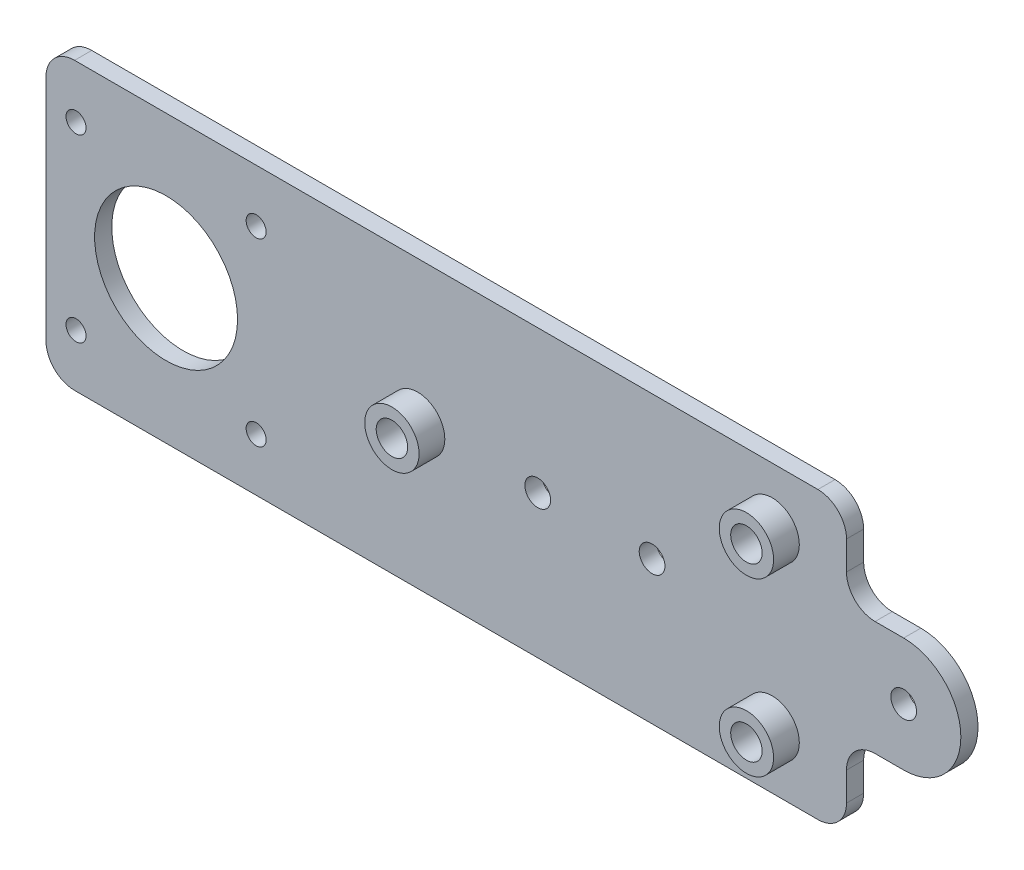
from build123d import *

# Parameters (mm, degrees)
BOSS_EXTRUDE1_DEPTH = 3
SKETCH2_R           = 1.75
SKETCH2_R_2         = 12.5
SKETCH2_R_3         = 2.75
CUT_EXTRUDE1_DEPTH  = 3
SKETCH3_R           = 4.75
SKETCH3_R_2         = 2.75
BOSS_EXTRUDE2_DEPTH = 4.5
SKETCH4_R           = 2.25
BOSS_EXTRUDE3_DEPTH = 3
FILLET1_R           = 5
SKETCH5_R           = 2.25
CUT_EXTRUDE2_DEPTH  = 4


with BuildPart() as part:
    # Sketch1 → Boss-Extrude1 (new body)
    with BuildSketch(Plane.XY):
        with BuildLine():
            Line((-65, 25), (65, 25))
            ThreePointArc((65, 25), (68.535533906, 23.535533906), (70, 20))
            Line((70, 20), (70, -20))
            ThreePointArc((70, -20), (68.535533906, -23.535533906), (65, -25))
            Line((65, -25), (-65, -25))
            ThreePointArc((-65, -25), (-68.535533906, -23.535533906), (-70, -20))
            Line((-70, -20), (-70, 20))
            ThreePointArc((-70, 20), (-68.535533906, 23.535533906), (-65, 25))
        make_face()
    extrude(amount=BOSS_EXTRUDE1_DEPTH)

    # Sketch2 → Cut-Extrude1 (cut)
    with BuildSketch(Plane.XY.offset(3)):
        with Locations((-64.75, 15.75)):
            Circle(SKETCH2_R)
        with Locations((-33.25, 15.75)):
            Circle(SKETCH2_R)
        with Locations((-64.75, -15.75)):
            Circle(SKETCH2_R)
        with Locations((-33.25, -15.75)):
            Circle(SKETCH2_R)
        with Locations((-49, 0)):
            Circle(SKETCH2_R_2)
        with Locations((57, 15)):
            Circle(SKETCH2_R_3)
        with Locations((57, -15)):
            Circle(SKETCH2_R_3)
        with Locations((-5, 0)):
            Circle(SKETCH2_R_3)
    extrude(amount=-CUT_EXTRUDE1_DEPTH, mode=Mode.SUBTRACT)

    # Sketch3 → Boss-Extrude2 (add)
    with BuildSketch(Plane.XY.offset(3)):
        with Locations((57, 15)):
            Circle(SKETCH3_R)
        with Locations((57, 15)):
            Circle(SKETCH3_R_2, mode=Mode.SUBTRACT)
        with Locations((-5, 0)):
            Circle(SKETCH3_R)
        with Locations((-5, 0)):
            Circle(SKETCH3_R_2, mode=Mode.SUBTRACT)
        with Locations((57, -15)):
            Circle(SKETCH3_R)
        with Locations((57, -15)):
            Circle(SKETCH3_R_2, mode=Mode.SUBTRACT)
    extrude(amount=BOSS_EXTRUDE2_DEPTH)

    # Sketch4 → Boss-Extrude3 (add)
    with BuildSketch(Plane.XY):
        with BuildLine():
            Line((70, 10), (70, -10))
            Line((70, -10), (80, -10))
            ThreePointArc((80, -10), (90, 0), (80, 10))
            Line((80, 10), (70, 10))
        make_face()
        with Locations((80, 0)):
            Circle(SKETCH4_R, mode=Mode.SUBTRACT)
    extrude(amount=BOSS_EXTRUDE3_DEPTH)

    # Fillet1
    fillet1_edges = [part.edges().sort_by_distance(p)[0] for p in [
        (70, -10, 1.5),
        (70, 10, 1.5),
    ]]
    fillet(fillet1_edges, radius=FILLET1_R)

    # Sketch5 → Cut-Extrude2 (cut, through all)
    with BuildSketch(Plane.XY.offset(3)):
        with Locations((16, 0)):
            Circle(SKETCH5_R)
        with Locations((36, 0)):
            Circle(SKETCH5_R)
    extrude(amount=-CUT_EXTRUDE2_DEPTH, mode=Mode.SUBTRACT)


solid = part.part
